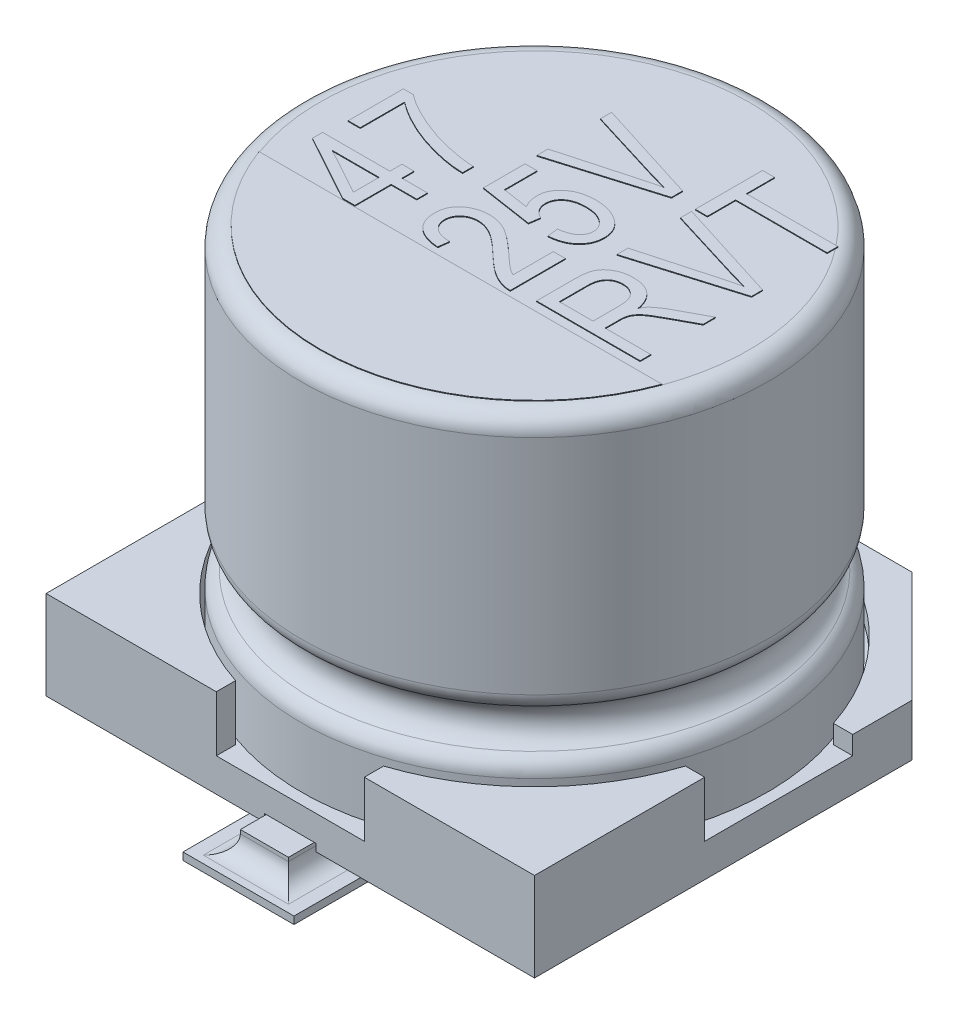
from build123d import *

# Parameters (mm, degrees)
SKETCH1_W                = 6.6
SKETCH1_H                = 6.6
BOSS_EXTRUDE1_DEPTH      = 1.2
CUT_EXTRUDE1_DEPTH       = 0.75
SKETCH3_W                = 3.3
SKETCH3_H                = 0.5
CUT_EXTRUDE2_DEPTH       = 5.902040392
CUT_EXTRUDE2_DEPTH_BACK  = 5.902040392
CHAMFER1_SIZE            = 1.5
CUT_EXTRUDE3_DEPTH       = 0.1
BOSS_EXTRUDE4_DEPTH      = 0.3
BOSS_EXTRUDE4_DEPTH_BACK = 0.1
SKETCH8_R                = 0.5
BOSS_EXTRUDE5_DEPTH      = 0.3
SKETCH9_W                = 1.5
SKETCH9_H                = 2
BOSS_EXTRUDE6_DEPTH      = 0.1
FILLET1_R                = 0.25
BOSS_EXTRUDE7_DEPTH      = 0.01


with BuildPart() as part:
    # Sketch1 → Boss-Extrude1 (new body)
    with BuildSketch(Plane(origin=(0, 0.3, 0), x_dir=(1, 0, 0), z_dir=(0, 1, 0))):
        Rectangle(SKETCH1_W, SKETCH1_H)
    extrude(amount=BOSS_EXTRUDE1_DEPTH)

    # Sketch2 → Cut-Extrude1 (cut)
    with BuildSketch(Plane(origin=(0, 1.5, 0), x_dir=(1, 0, 0), z_dir=(0, 1, 0))):
        with BuildLine():
            Line((-3.3, 1), (-3.039736831, 1))
            ThreePointArc((-3.039736831, 1), (-2.2627417, 2.2627417), (-1, 3.039736831))
            Line((-1, 3.039736831), (-1, 3.3))
            Line((-1, 3.3), (1, 3.3))
            Line((1, 3.3), (1, 3.039736831))
            ThreePointArc((1, 3.039736831), (2.2627417, 2.2627417), (3.039736831, 1))
            Line((3.039736831, 1), (3.3, 1))
            Line((3.3, 1), (3.3, -1))
            Line((3.3, -1), (3.039736831, -1))
            ThreePointArc((3.039736831, -1), (2.2627417, -2.2627417), (1, -3.039736831))
            Line((1, -3.039736831), (1, -3.3))
            Line((1, -3.3), (-1, -3.3))
            Line((-1, -3.3), (-1, -3.039736831))
            ThreePointArc((-1, -3.039736831), (-2.2627417, -2.2627417), (-3.039736831, -1))
            Line((-3.039736831, -1), (-3.3, -1))
            Line((-3.3, -1), (-3.3, 1))
        make_face()
    extrude(amount=-CUT_EXTRUDE1_DEPTH, mode=Mode.SUBTRACT)

    # Sketch3 → Cut-Extrude2 (cut, two sides)
    with BuildSketch(Plane(origin=(0, 0, 0), x_dir=(0, 0, -1), z_dir=(1, 0, 0))) as cut_extrude2_sk:
        with Locations((1.65, 1.25)):
            Rectangle(SKETCH3_W, SKETCH3_H)
    extrude(amount=CUT_EXTRUDE2_DEPTH, mode=Mode.SUBTRACT)
    extrude(cut_extrude2_sk.sketch, amount=-CUT_EXTRUDE2_DEPTH_BACK, mode=Mode.SUBTRACT)

    # Chamfer1
    chamfer1_edges = [part.edges().sort_by_distance(p)[0] for p in [
        (3.3, 0.65, -3.3),
        (-3.3, 0.65, -3.3),
    ]]
    chamfer(chamfer1_edges, length=CHAMFER1_SIZE)

    # Sketch7 → Cut-Extrude3 (cut)
    with BuildSketch(Plane.XZ.offset(-0.3)):
        with BuildLine():
            Line((-0.35, 3.3), (0.35, 3.3))
            Line((0.35, 3.3), (0.498675617, 1.261367968))
            ThreePointArc((0.498675617, 1.261367968), (0, 0.725), (-0.498675617, 1.261367968))
            Line((-0.498675617, 1.261367968), (-0.35, 3.3))
        make_face()
        with BuildLine():
            Line((-0.35, -3.3), (0.35, -3.3))
            Line((0.35, -3.3), (0.498675617, -1.261367968))
            ThreePointArc((0.498675617, -1.261367968), (0, -0.725), (-0.498675617, -1.261367968))
            Line((-0.498675617, -1.261367968), (-0.35, -3.3))
        make_face()
    extrude(amount=-CUT_EXTRUDE3_DEPTH, mode=Mode.SUBTRACT)

    # Sketch6 → Boss-Extrude4 (add, two sides)
    with BuildSketch(Plane.XZ.offset(-0.3)) as boss_extrude4_sk:
        with BuildLine():
            Line((-0.325, -1.225), (-0.325, -3.65))
            Line((-0.325, -3.65), (0.325, -3.65))
            Line((0.325, -3.65), (0.325, -1.225))
            ThreePointArc((0.325, -1.225), (0, -0.9), (-0.325, -1.225))
        make_face()
        with BuildLine():
            Line((-0.325, 1.225), (-0.325, 3.65))
            Line((-0.325, 3.65), (0.325, 3.65))
            Line((0.325, 3.65), (0.325, 1.225))
            ThreePointArc((0.325, 1.225), (0, 0.9), (-0.325, 1.225))
        make_face()
    extrude(amount=BOSS_EXTRUDE4_DEPTH)
    extrude(boss_extrude4_sk.sketch, amount=-BOSS_EXTRUDE4_DEPTH_BACK)

    # Sketch8 → Boss-Extrude5 (add)
    with BuildSketch(Plane.XZ.offset(-0.3)):
        with Locations(Location((-2, 2, 0), (0, 0, 270))):
            Circle(SKETCH8_R)
        with Locations(Location((2, 2, 0), (0, 0, 270))):
            Circle(SKETCH8_R)
        with Locations(Location((2, -2, 0), (0, 0, 270))):
            Circle(SKETCH8_R)
        with Locations(Location((-2, -2, 0), (0, 0, 270))):
            Circle(SKETCH8_R)
    extrude(amount=BOSS_EXTRUDE5_DEPTH)

    # Sketch9 → Boss-Extrude6 (add)
    with BuildSketch(Plane(origin=(0, 0, 0), x_dir=(1, 0, 0), z_dir=(0, 1, 0))):
        with Locations((0, 3)):
            Rectangle(SKETCH9_W, SKETCH9_H)
        with Locations((0, -3)):
            Rectangle(SKETCH9_W, SKETCH9_H)
    extrude(amount=BOSS_EXTRUDE6_DEPTH)

    # Fillet1
    fillet1_edges = [part.edges().sort_by_distance(p)[0] for p in [
        (0.325, 0.1, -2.825),
        (0, 0.1, -3.65),
        (-0.325, 0.1, -2.825),
        (-0.325, 0.1, 2.825),
        (0, 0.1, 3.65),
        (0.325, 0.1, 2.825),
    ]]
    fillet(fillet1_edges, radius=FILLET1_R)


with BuildPart() as body_2:
    # Sketch4 → Revolve1 (revolve)
    with BuildSketch(Plane(origin=(0, 0, 0), x_dir=(0, 0, -1), z_dir=(1, 0, 0)), mode=Mode.PRIVATE) as revolve1_sk:
        with BuildLine():
            Line((0, 0.75), (0, 5.8))
            Line((0, 5.8), (-2.9, 5.8))
            ThreePointArc((-2.9, 5.8), (-3.076776695, 5.726776695), (-3.15, 5.55))
            Line((-3.15, 5.55), (-3.15, 2.539897949))
            ThreePointArc((-3.15, 2.539897949), (-3.113200716, 2.409339707), (-3.013636364, 2.317217063))
            ThreePointArc((-3.013636364, 2.317217063), (-2.85, 2.05), (-3.013636364, 1.782782937))
            ThreePointArc((-3.013636364, 1.782782937), (-3.113200716, 1.690660293), (-3.15, 1.560102051))
            Line((-3.15, 1.560102051), (-3.15, 0.75))
            Line((-3.15, 0.75), (0, 0.75))
        make_face()
    revolve(revolve1_sk.sketch.rotate(Axis((0, 0, 0), (0, 1, 0)), 180), axis=Axis((0, 0, 0), (0, 1, 0)))

    # Sketch10 → Boss-Extrude7 (add)
    with BuildSketch(Plane(origin=(0, 5.8, 0), x_dir=(1, 0, 0), z_dir=(0, 1, 0))):
        with BuildLine():
            Line((-2.722131518, -1), (2.722131518, -1))
            ThreePointArc((2.722131518, -1), (0, -2.9), (-2.722131518, -1))
        make_face()
        Polygon((-1.1, -0.490909091), (-1.445454545, -0.490909091), (-1.445454545, -0.981818182), (-1.609090909, -0.981818182), (-2.518181818, -0.482670455), (-2.518181818, -0.345454545), (-1.609090909, -0.345454545), (-1.609090909, -0.181818182), (-1.445454545, -0.181818182), (-1.445454545, -0.345454545), (-1.1, -0.345454545), align=None)
        Polygon((-1.609090909, -0.490909091), (-2.241761364, -0.490909091), (-1.609090909, -0.838352273), align=None, mode=Mode.SUBTRACT)
        with BuildLine():
            Line((-2.318181818, -0.036363636), (-2.481818182, -0.036363636))
            Line((-2.481818182, -0.036363636), (-2.481818182, 0.709090909))
            Line((-2.481818182, 0.709090909), (-2.348011364, 0.709090909))
            add(Edge.make_bspline(
                [(-2.348011364, 0.709090909), (-2.329493997, 0.695259816), (-2.291802758, 0.667107268), (-2.231511589, 0.627736674), (-2.167300458, 0.589447284), (-2.099115474, 0.552202178), (-2.026735965, 0.516442976), (-1.950395077, 0.481792677), (-1.869863353, 0.448671938), (-1.786180255, 0.416771358), (-1.700509186, 0.387072726), (-1.614166454, 0.360699392), (-1.527962748, 0.337560436), (-1.441958888, 0.318119267), (-1.356259293, 0.301430866), (-1.270766825, 0.288433289), (-1.185381408, 0.278624638), (-1.128427711, 0.274690798), (-1.1, 0.272727273)],
                knots=[0, 0, 0, 0, 0.828228242, 1.685820058, 2.579325365, 3.507361607, 4.469713273, 5.472243924, 6.511632332, 7.590183537, 8.68180921, 9.76082494, 10.825356942, 11.880104434, 12.920528634, 13.95402052, 14.978775448, 16, 16, 16, 16], degree=3))
            Line((-1.1, 0.272727273), (-1.1, 0.127272727))
            add(Edge.make_bspline(
                [(-1.1, 0.127272727), (-1.114968384, 0.127721783), (-1.145503887, 0.128637858), (-1.192187637, 0.132321595), (-1.240736039, 0.136926159), (-1.291101377, 0.14395977), (-1.343309321, 0.152404131), (-1.397339203, 0.16282712), (-1.453308412, 0.174269157), (-1.530001628, 0.192613669), (-1.62599912, 0.218383212), (-1.739052852, 0.255716866), (-1.849665888, 0.297377526), (-1.956248385, 0.345139752), (-2.057722591, 0.395822213), (-2.151901767, 0.449612447), (-2.239097534, 0.503996466), (-2.292310728, 0.544126176), (-2.318181818, 0.563636364)],
                knots=[0, 0, 0, 0, 0.547560405, 1.117023226, 1.712128439, 2.330702075, 2.976322001, 3.646013224, 4.342857794, 5.065247493, 6.529539093, 7.976213993, 9.417556904, 10.850065343, 12.245478746, 13.563746768, 14.815546979, 16, 16, 16, 16], degree=3))
            Line((-2.318181818, 0.563636364), (-2.318181818, -0.036363636))
        make_face()
        with BuildLine():
            Line((0.436363636, -0.181818182), (0.6, -0.181818182))
            Line((0.6, -0.181818182), (0.6, -0.927272727))
            add(Edge.make_bspline(
                [(0.6, -0.927272727), (0.591473861, -0.927307242), (0.574199763, -0.92737717), (0.547863878, -0.925052284), (0.520890384, -0.920275608), (0.492919456, -0.914176275), (0.464318953, -0.905528107), (0.434949982, -0.894941063), (0.404885362, -0.882449608), (0.373948232, -0.867821951), (0.341836986, -0.85073411), (0.308706054, -0.830091775), (0.273939944, -0.806503171), (0.237972195, -0.779396799), (0.200460941, -0.749260325), (0.161579918, -0.715945027), (0.121115489, -0.679590037), (0.094239066, -0.65368301), (0.080397727, -0.640340909)],
                knots=[0, 0, 0, 0, 0.672196011, 1.361880106, 2.081368845, 2.831486093, 3.618364569, 4.435734711, 5.292876118, 6.184871288, 7.133796945, 8.159796293, 9.26180684, 10.446293416, 11.710635831, 13.056147575, 14.483918136, 16, 16, 16, 16], degree=3))
            add(Edge.make_bspline(
                [(0.080397727, -0.640340909), (0.064362729, -0.624838105), (0.033488588, -0.594988661), (-0.012098974, -0.552978419), (-0.054472047, -0.514807895), (-0.09439686, -0.481239711), (-0.131329649, -0.45167791), (-0.165217609, -0.425825067), (-0.196829804, -0.404916689), (-0.234026094, -0.382341586), (-0.278307687, -0.360819433), (-0.329924889, -0.34179263), (-0.379823364, -0.329498879), (-0.412720366, -0.328000332), (-0.428693182, -0.327272727)],
                knots=[0, 0, 0, 0, 1.312560889, 2.527233899, 3.64818266, 4.668586789, 5.596397896, 6.432357998, 7.175835261, 7.825761013, 8.992224112, 10.065918602, 11.060925749, 12, 12, 12, 12], degree=3))
            add(Edge.make_bspline(
                [(-0.428693182, -0.327272727), (-0.437511466, -0.327374155), (-0.454734496, -0.327572254), (-0.479886592, -0.330939934), (-0.50381126, -0.335740808), (-0.526676172, -0.34208599), (-0.548124534, -0.351058455), (-0.568306101, -0.361931274), (-0.58748668, -0.374364054), (-0.605000247, -0.388871949), (-0.620799928, -0.404730101), (-0.634944309, -0.421482723), (-0.64650537, -0.439412197), (-0.656081715, -0.458149046), (-0.663408979, -0.477805517), (-0.668899131, -0.498331952), (-0.672018106, -0.519791199), (-0.67248854, -0.534365371), (-0.672727273, -0.541761364)],
                knots=[0, 0, 0, 0, 1.164144409, 2.273695819, 3.345940663, 4.387378487, 5.402712487, 6.410231049, 7.41307794, 8.417484468, 9.408318902, 10.367853362, 11.308274301, 12.220303706, 13.142827832, 14.074469365, 15.022846069, 16, 16, 16, 16], degree=3))
            add(Edge.make_bspline(
                [(-0.672727273, -0.541761364), (-0.67256065, -0.549735789), (-0.672235395, -0.565302234), (-0.66816798, -0.58798478), (-0.662773189, -0.609744121), (-0.654244328, -0.630308269), (-0.64393617, -0.650068929), (-0.630480705, -0.668213205), (-0.615464229, -0.685784601), (-0.597847597, -0.701936563), (-0.577843958, -0.716354261), (-0.555995759, -0.729295972), (-0.531759102, -0.739727099), (-0.505732976, -0.748493339), (-0.477605795, -0.755379216), (-0.447464409, -0.759976594), (-0.415321715, -0.763349713), (-0.393191418, -0.763539056), (-0.381818182, -0.763636364)],
                knots=[0, 0, 0, 0, 0.928593091, 1.812656339, 2.680433, 3.537535669, 4.402074609, 5.272376737, 6.164676777, 7.094647554, 8.050991042, 9.035788945, 10.049325173, 11.121325706, 12.235436061, 13.420862991, 14.67452591, 16, 16, 16, 16], degree=3))
            Line((-0.381818182, -0.763636364), (-0.4, -0.909090909))
            add(Edge.make_bspline(
                [(-0.4, -0.909090909), (-0.416878864, -0.907591961), (-0.449624625, -0.904683933), (-0.497028868, -0.897053486), (-0.541012726, -0.886466967), (-0.582009501, -0.87389317), (-0.619529308, -0.858098246), (-0.654259092, -0.840320731), (-0.685594771, -0.819531651), (-0.71358887, -0.796165061), (-0.738135931, -0.770416762), (-0.759470498, -0.742754936), (-0.777973713, -0.713309743), (-0.792661358, -0.681666753), (-0.804113656, -0.648035286), (-0.812301557, -0.612540687), (-0.817184689, -0.575040843), (-0.817844532, -0.549446474), (-0.818181818, -0.536363636)],
                knots=[0, 0, 0, 0, 1.296016433, 2.514330702, 3.668705393, 4.754684394, 5.790583066, 6.778804856, 7.735156204, 8.660808185, 9.562568342, 10.450784178, 11.329227516, 12.217177451, 13.112894374, 14.042449809, 14.999377131, 16, 16, 16, 16], degree=3))
            add(Edge.make_bspline(
                [(-0.818181818, -0.536363636), (-0.81777024, -0.522237085), (-0.81696883, -0.494730344), (-0.811606791, -0.45470806), (-0.802364468, -0.417268646), (-0.788775473, -0.382683468), (-0.772086687, -0.350576525), (-0.751359855, -0.321238205), (-0.726718946, -0.294699063), (-0.698630231, -0.271102577), (-0.668318477, -0.250243504), (-0.636619301, -0.232044118), (-0.604062219, -0.216257213), (-0.570283829, -0.203919398), (-0.535737761, -0.193615982), (-0.499900262, -0.187143157), (-0.463184854, -0.182586333), (-0.438366747, -0.182075678), (-0.425852273, -0.181818182)],
                knots=[0, 0, 0, 0, 1.141316638, 2.222333051, 3.255980828, 4.24919085, 5.217781249, 6.173073686, 7.14226832, 8.135684626, 9.131102602, 10.111468148, 11.086834621, 12.050425614, 13.014198859, 13.995608887, 14.989290351, 16, 16, 16, 16], degree=3))
            add(Edge.make_bspline(
                [(-0.425852273, -0.181818182), (-0.41457728, -0.182060793), (-0.392174188, -0.182542853), (-0.358747505, -0.185678697), (-0.325770218, -0.191214046), (-0.292925237, -0.198401446), (-0.260721139, -0.208600438), (-0.228646367, -0.220146162), (-0.197063055, -0.234150534), (-0.165353596, -0.250681871), (-0.132400362, -0.270042705), (-0.097582813, -0.293222701), (-0.05999161, -0.319941246), (-0.020068327, -0.350742095), (0.022628597, -0.385133141), (0.067760296, -0.423558024), (0.115418934, -0.465887373), (0.147774758, -0.495686412), (0.164488636, -0.511079545)],
                knots=[0, 0, 0, 0, 0.780531358, 1.550893666, 2.321451189, 3.094347453, 3.876089108, 4.657940698, 5.453333384, 6.265487087, 7.132311241, 8.097757185, 9.160053187, 10.324349312, 11.587703087, 12.955031265, 14.427076445, 16, 16, 16, 16], degree=3))
            add(Edge.make_bspline(
                [(0.164488636, -0.511079545), (0.174879317, -0.520861385), (0.194736743, -0.539555267), (0.223540483, -0.565848432), (0.249372468, -0.589941919), (0.272886624, -0.611016769), (0.293579301, -0.62975731), (0.312127711, -0.645161778), (0.327628216, -0.658406993), (0.352466614, -0.677729847), (0.387502286, -0.70211597), (0.420452127, -0.719080527), (0.436363636, -0.727272727)],
                knots=[0, 0, 0, 0, 1.227426371, 2.345710398, 3.354421158, 4.265580894, 5.061720194, 5.755250507, 6.339260457, 6.815034732, 8.461977265, 10, 10, 10, 10], degree=3))
            Line((0.436363636, -0.727272727), (0.436363636, -0.181818182))
        make_face()
        with BuildLine():
            Line((0.218181818, -0.036363636), (0.2, 0.109090909))
            add(Edge.make_bspline(
                [(0.2, 0.109090909), (0.211101971, 0.110567587), (0.232737788, 0.113445378), (0.263885694, 0.119848382), (0.293064038, 0.126930845), (0.319651618, 0.136285915), (0.34447028, 0.146000707), (0.366780938, 0.157754603), (0.387216311, 0.170429338), (0.405044464, 0.184825644), (0.42111939, 0.19975374), (0.434636833, 0.215785653), (0.446561389, 0.232076172), (0.456229143, 0.249117635), (0.463723293, 0.266844238), (0.468775385, 0.285197267), (0.472033163, 0.304051607), (0.472494528, 0.316842721), (0.472727273, 0.323295455)],
                knots=[0, 0, 0, 0, 1.411589299, 2.750942728, 4.00771248, 5.193274551, 6.301848483, 7.364530321, 8.36815806, 9.328452501, 10.249032995, 11.129646394, 11.967965374, 12.7913576, 13.594060915, 14.387835106, 15.186711129, 16, 16, 16, 16], degree=3))
            add(Edge.make_bspline(
                [(0.472727273, 0.323295455), (0.47246113, 0.331363756), (0.471934427, 0.347331097), (0.46751459, 0.370816108), (0.460368895, 0.393421364), (0.450386963, 0.415271865), (0.43708047, 0.435936311), (0.421405758, 0.456119122), (0.402468066, 0.474980646), (0.381218628, 0.493183371), (0.357552586, 0.510017788), (0.331144397, 0.524080821), (0.302921326, 0.536308638), (0.27269317, 0.546702043), (0.240203605, 0.554209971), (0.20572194, 0.559481998), (0.169202922, 0.563055128), (0.1441377, 0.563438993), (0.13125, 0.563636364)],
                knots=[0, 0, 0, 0, 0.833503236, 1.64952068, 2.460650161, 3.279715081, 4.124353123, 4.995793989, 5.916428404, 6.881576056, 7.886415737, 8.911413223, 9.967990459, 11.063833818, 12.210651719, 13.409634283, 14.668120429, 16, 16, 16, 16], degree=3))
            add(Edge.make_bspline(
                [(0.13125, 0.563636364), (0.119216027, 0.563411231), (0.095769358, 0.56297259), (0.061609862, 0.559772504), (0.029473354, 0.554831228), (-0.000594739, 0.547469608), (-0.028423842, 0.537659446), (-0.054490961, 0.526502629), (-0.078298563, 0.512722984), (-0.099725125, 0.496779871), (-0.119111641, 0.479625248), (-0.135710672, 0.460896308), (-0.149925684, 0.441323642), (-0.161929936, 0.420707247), (-0.170475105, 0.398657339), (-0.177295763, 0.375820096), (-0.180872766, 0.351720796), (-0.181499254, 0.335331824), (-0.181818182, 0.326988636)],
                knots=[0, 0, 0, 0, 1.312040837, 2.556345105, 3.737883698, 4.854849349, 5.925960309, 6.952388988, 7.9424386, 8.917239489, 9.860521384, 10.760061641, 11.639947922, 12.495504232, 13.352616949, 14.212152034, 15.089854369, 16, 16, 16, 16], degree=3))
            add(Edge.make_bspline(
                [(-0.181818182, 0.326988636), (-0.181386991, 0.31691141), (-0.180526809, 0.296808367), (-0.173354012, 0.267203557), (-0.161919921, 0.238576183), (-0.145949551, 0.211277017), (-0.125781986, 0.186087196), (-0.101844533, 0.163424776), (-0.074502628, 0.143327785), (-0.054133578, 0.132693693), (-0.04375, 0.127272727)],
                knots=[0, 0, 0, 0, 0.943121662, 1.881431981, 2.836990949, 3.823036868, 4.833137184, 5.849762362, 6.903868453, 8, 8, 8, 8], degree=3))
            Line((-0.04375, 0.127272727), (-0.064488636, -0.018181818))
            Line((-0.064488636, -0.018181818), (-0.781818182, 0.090909091))
            Line((-0.781818182, 0.090909091), (-0.781818182, 0.654545455))
            Line((-0.781818182, 0.654545455), (-0.618181818, 0.654545455))
            Line((-0.618181818, 0.654545455), (-0.618181818, 0.212784091))
            Line((-0.618181818, 0.212784091), (-0.272443182, 0.160227273))
            add(Edge.make_bspline(
                [(-0.272443182, 0.160227273), (-0.280823021, 0.176613081), (-0.297407403, 0.209041926), (-0.314678944, 0.260640587), (-0.32533713, 0.313667947), (-0.326625365, 0.349571453), (-0.327272727, 0.367613636)],
                knots=[0, 0, 0, 0, 1.017619267, 2.013951072, 3.001973272, 4, 4, 4, 4], degree=3))
            add(Edge.make_bspline(
                [(-0.327272727, 0.367613636), (-0.326874523, 0.378906499), (-0.326083106, 0.401350674), (-0.320235417, 0.434343157), (-0.310874813, 0.466250024), (-0.297294668, 0.496922513), (-0.279916146, 0.526376693), (-0.258874387, 0.554832977), (-0.234130638, 0.58215363), (-0.205438517, 0.607756331), (-0.173874347, 0.631620275), (-0.139218461, 0.652454829), (-0.10193904, 0.670137284), (-0.061857834, 0.684168416), (-0.019379192, 0.695726579), (0.025894119, 0.703532212), (0.073772199, 0.708019966), (0.106524397, 0.708728234), (0.123295455, 0.709090909)],
                knots=[0, 0, 0, 0, 0.861018809, 1.711245113, 2.547675859, 3.391805506, 4.262674834, 5.151129072, 6.086914488, 7.068866089, 8.080081396, 9.100796714, 10.1476286, 11.221399762, 12.335728169, 13.501851446, 14.720800604, 16, 16, 16, 16], degree=3))
            add(Edge.make_bspline(
                [(0.123295455, 0.709090909), (0.139972763, 0.708744866), (0.172829781, 0.708063103), (0.221182639, 0.703234952), (0.267685748, 0.694930211), (0.312341106, 0.683620509), (0.355233532, 0.669108797), (0.396299037, 0.651153258), (0.435499753, 0.629784545), (0.472612172, 0.605560487), (0.506510629, 0.57857772), (0.53647709, 0.549082485), (0.561857129, 0.517280497), (0.582560215, 0.483088947), (0.598604448, 0.446704241), (0.609942787, 0.408034652), (0.616952086, 0.367110572), (0.617766217, 0.339043658), (0.618181818, 0.324715909)],
                knots=[0, 0, 0, 0, 1.144492614, 2.254837035, 3.330813134, 4.383755227, 5.413414698, 6.434919789, 7.455680344, 8.474121079, 9.472858394, 10.424138735, 11.353862604, 12.257787762, 13.159841921, 14.074912736, 15.017271142, 16, 16, 16, 16], degree=3))
            add(Edge.make_bspline(
                [(0.618181818, 0.324715909), (0.617828765, 0.312771431), (0.617133725, 0.289256917), (0.612395275, 0.254615174), (0.603577826, 0.221636349), (0.592442177, 0.189715236), (0.577096784, 0.15959834), (0.55888353, 0.130664995), (0.537105731, 0.103295459), (0.512134892, 0.077568051), (0.484458274, 0.053758215), (0.454005872, 0.032531418), (0.420992011, 0.014069776), (0.385306503, -0.001590372), (0.347111633, -0.014252186), (0.306479895, -0.024498815), (0.263297216, -0.032285998), (0.233456651, -0.03498306), (0.218181818, -0.036363636)],
                knots=[0, 0, 0, 0, 0.958689857, 1.887326147, 2.797936266, 3.6946441, 4.595336751, 5.504073741, 6.434636212, 7.396724143, 8.377688541, 9.360182663, 10.370759081, 11.408658253, 12.482955239, 13.5963024, 14.769591684, 16, 16, 16, 16], degree=3))
        make_face()
        with BuildLine():
            Line((0.6, 1.250852273), (-0.8, 0.832102273))
            Line((-0.8, 0.832102273), (-0.8, 0.981818182))
            Line((-0.8, 0.981818182), (0.215625, 1.261931818))
            add(Edge.make_bspline(
                [(0.215625, 1.261931818), (0.23502513, 1.267188611), (0.273113627, 1.277509333), (0.329419911, 1.291882434), (0.383540048, 1.305617864), (0.419023676, 1.314057553), (0.436363636, 1.318181818)],
                knots=[0, 0, 0, 0, 1.058778416, 2.078711773, 3.061114545, 4, 4, 4, 4], degree=3))
            add(Edge.make_bspline(
                [(0.436363636, 1.318181818), (0.400128509, 1.327526981), (0.326165891, 1.346602192), (0.252964299, 1.368417642), (0.215625, 1.379545455)],
                knots=[0, 0, 0, 0, 0.979822753, 2, 2, 2, 2], degree=3))
            Line((0.215625, 1.379545455), (-0.8, 1.690909091))
            Line((-0.8, 1.690909091), (-0.8, 1.842045455))
            Line((-0.8, 1.842045455), (0.6, 1.401136364))
            Line((0.6, 1.401136364), (0.6, 1.250852273))
        make_face()
        with BuildLine():
            Line((2.3, -0.872727273), (0.9, -0.872727273))
            Line((0.9, -0.872727273), (0.9, -0.358522727))
            add(Edge.make_bspline(
                [(0.9, -0.358522727), (0.900073763, -0.345546017), (0.900216539, -0.320428259), (0.902308959, -0.284044497), (0.905344787, -0.250202662), (0.909579597, -0.219012834), (0.914777868, -0.190483154), (0.921766894, -0.16473241), (0.929434889, -0.141402667), (0.942097141, -0.11394169), (0.962104286, -0.08285306), (0.991986148, -0.049045543), (1.029113573, -0.019546227), (1.071726678, 0.006727276), (1.11958402, 0.028297408), (1.17177175, 0.043578157), (1.22760849, 0.052802429), (1.266062455, 0.053954341), (1.285795455, 0.054545455)],
                knots=[0, 0, 0, 0, 0.957632509, 1.853596319, 2.688865688, 3.464800978, 4.176232129, 4.827248354, 5.432859936, 5.986426289, 7.054779681, 8.148885667, 9.301586196, 10.541074307, 11.836203864, 13.163061816, 14.544199576, 16, 16, 16, 16], degree=3))
            add(Edge.make_bspline(
                [(1.285795455, 0.054545455), (1.298871698, 0.054235333), (1.32441369, 0.053629569), (1.361855278, 0.049987367), (1.397440244, 0.043563031), (1.430988976, 0.034018043), (1.462814114, 0.022553984), (1.492482956, 0.007839851), (1.520425409, -0.009159596), (1.546408208, -0.028871174), (1.570251677, -0.051075165), (1.592091252, -0.075549512), (1.611022928, -0.102851103), (1.628180904, -0.132133088), (1.642985373, -0.163902878), (1.65548257, -0.198004739), (1.665367052, -0.234558689), (1.67023708, -0.259813647), (1.672727273, -0.272727273)],
                knots=[0, 0, 0, 0, 1.121876415, 2.19137531, 3.223949102, 4.219388443, 5.180726412, 6.121767895, 7.055309798, 7.98310721, 8.914383918, 9.846793912, 10.791230962, 11.759648879, 12.755485972, 13.793860249, 14.871933835, 16, 16, 16, 16], degree=3))
            add(Edge.make_bspline(
                [(1.672727273, -0.272727273), (1.677972871, -0.263164174), (1.687983581, -0.244913937), (1.704620081, -0.220357649), (1.720557857, -0.198837772), (1.732437343, -0.186905744), (1.738068182, -0.18125)],
                knots=[0, 0, 0, 0, 1.159024517, 2.21188481, 3.152438931, 4, 4, 4, 4], degree=3))
            add(Edge.make_bspline(
                [(1.738068182, -0.18125), (1.751761893, -0.169905132), (1.779303299, -0.147087825), (1.82324216, -0.115808927), (1.868950866, -0.085847863), (1.901104584, -0.068253316), (1.917329545, -0.059375)],
                knots=[0, 0, 0, 0, 0.982253192, 1.975551771, 2.978451105, 4, 4, 4, 4], degree=3))
            Line((1.917329545, -0.059375), (2.3, 0.145454545))
            Line((2.3, 0.145454545), (2.3, -0.019886364))
            Line((2.3, -0.019886364), (2.000568182, -0.181534091))
            add(Edge.make_bspline(
                [(2.000568182, -0.181534091), (1.986528238, -0.189064398), (1.959673176, -0.203468078), (1.921542639, -0.224844268), (1.887155621, -0.244716202), (1.856473931, -0.26304488), (1.829837697, -0.28011911), (1.806835821, -0.29541567), (1.787807022, -0.309583774), (1.767901985, -0.326061224), (1.747867101, -0.345925096), (1.727397014, -0.368993525), (1.711579168, -0.392199546), (1.699513707, -0.415799766), (1.691569692, -0.441785471), (1.685622134, -0.471064256), (1.682387461, -0.504948189), (1.682015972, -0.528971003), (1.681818182, -0.541761364)],
                knots=[0, 0, 0, 0, 1.483604313, 2.837780862, 4.070509745, 5.182094193, 6.165504003, 7.016659521, 7.753887315, 8.373758725, 9.421416007, 10.377927395, 11.24132908, 12.030078718, 12.836042303, 13.763032878, 14.808981517, 16, 16, 16, 16], degree=3))
            Line((1.681818182, -0.541761364), (1.681818182, -0.727272727))
            Line((1.681818182, -0.727272727), (2.3, -0.727272727))
            Line((2.3, -0.727272727), (2.3, -0.872727273))
        make_face()
        with BuildLine():
            Line((1.518181818, -0.727272727), (1.518181818, -0.386079545))
            add(Edge.make_bspline(
                [(1.518181818, -0.386079545), (1.51784038, -0.368551478), (1.517200491, -0.33570217), (1.512950466, -0.289746201), (1.505260087, -0.250520807), (1.494057811, -0.217296065), (1.479219373, -0.188958415), (1.460827249, -0.164309705), (1.438869635, -0.14255013), (1.413289498, -0.12443297), (1.385178927, -0.108949222), (1.354131271, -0.098784902), (1.321145845, -0.091792043), (1.298334339, -0.0912082), (1.286647727, -0.090909091)],
                knots=[0, 0, 0, 0, 1.473137061, 2.760802605, 3.873686451, 4.825077919, 5.697275026, 6.550455577, 7.400251438, 8.283812568, 9.177530931, 10.086115457, 11.019493646, 12, 12, 12, 12], degree=3))
            add(Edge.make_bspline(
                [(1.286647727, -0.090909091), (1.278213117, -0.091167916), (1.261769623, -0.091672503), (1.237673197, -0.0944289), (1.215017199, -0.0995137), (1.19372088, -0.106728841), (1.173827875, -0.115709596), (1.155330151, -0.126983949), (1.138402828, -0.140382054), (1.122625811, -0.155455071), (1.108512425, -0.172607295), (1.096745483, -0.19208158), (1.086418458, -0.213266004), (1.077823559, -0.236448353), (1.071407677, -0.261698229), (1.066974643, -0.288890824), (1.064002815, -0.317926589), (1.063761011, -0.337965593), (1.063636364, -0.348295455)],
                knots=[0, 0, 0, 0, 1.044922679, 2.037104192, 2.998871072, 3.914999749, 4.817741419, 5.696780486, 6.590716951, 7.486574954, 8.395164589, 9.332593663, 10.297787276, 11.310892337, 12.389055078, 13.518989792, 14.721069654, 16, 16, 16, 16], degree=3))
            Line((1.063636364, -0.348295455), (1.063636364, -0.727272727))
            Line((1.063636364, -0.727272727), (1.518181818, -0.727272727))
        make_face(mode=Mode.SUBTRACT)
        with BuildLine():
            Line((2.3, 0.632670455), (0.9, 0.213920455))
            Line((0.9, 0.213920455), (0.9, 0.363636364))
            Line((0.9, 0.363636364), (1.915625, 0.64375))
            add(Edge.make_bspline(
                [(1.915625, 0.64375), (1.93502513, 0.649006793), (1.973113627, 0.659327515), (2.029419911, 0.673700615), (2.083540048, 0.687436046), (2.119023676, 0.695875735), (2.136363636, 0.7)],
                knots=[0, 0, 0, 0, 1.058778416, 2.078711773, 3.061114545, 4, 4, 4, 4], degree=3))
            add(Edge.make_bspline(
                [(2.136363636, 0.7), (2.100128509, 0.709345163), (2.026165891, 0.728420374), (1.952964299, 0.750235824), (1.915625, 0.761363636)],
                knots=[0, 0, 0, 0, 0.979822753, 2, 2, 2, 2], degree=3))
            Line((1.915625, 0.761363636), (0.9, 1.072727273))
            Line((0.9, 1.072727273), (0.9, 1.223863636))
            Line((0.9, 1.223863636), (2.3, 0.782954545))
            Line((2.3, 0.782954545), (2.3, 0.632670455))
        make_face()
        Polygon((2.3, 1.654545455), (1.063636364, 1.654545455), (1.063636364, 1.272727273), (0.9, 1.272727273), (0.9, 2.181818182), (1.063636364, 2.181818182), (1.063636364, 1.8), (2.3, 1.8), align=None)
    extrude(amount=BOSS_EXTRUDE7_DEPTH)


solid = Compound([part.part, body_2.part])
